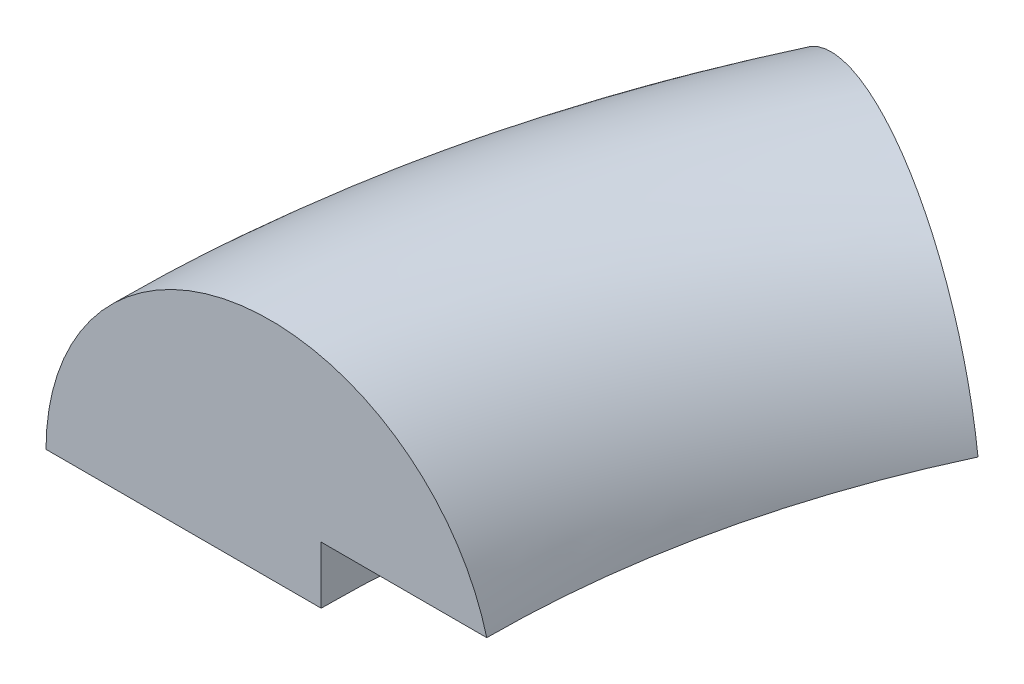
from build123d import *

# Parameters (mm, degrees)
REVOLVE1_ANGLE = 25


with BuildPart() as part:
    # Sketch3 → Revolve1 (revolve)
    with BuildSketch(Plane.XY):
        with BuildLine():
            Line((-25.3, 0), (-20.3, 0))
            Line((-20.3, 0), (-20.3, 1.040846003))
            Line((-20.3, 1.040846003), (-17.290442791, 1.040846003))
            ThreePointArc((-17.290442791, 1.040846003), (-21.752390995, 4.038451655), (-25.3, 0))
        make_face()
    revolve(axis=Axis((0, 5.058953412, 0), (0, -1, 0)), revolution_arc=REVOLVE1_ANGLE)


solid = part.part
